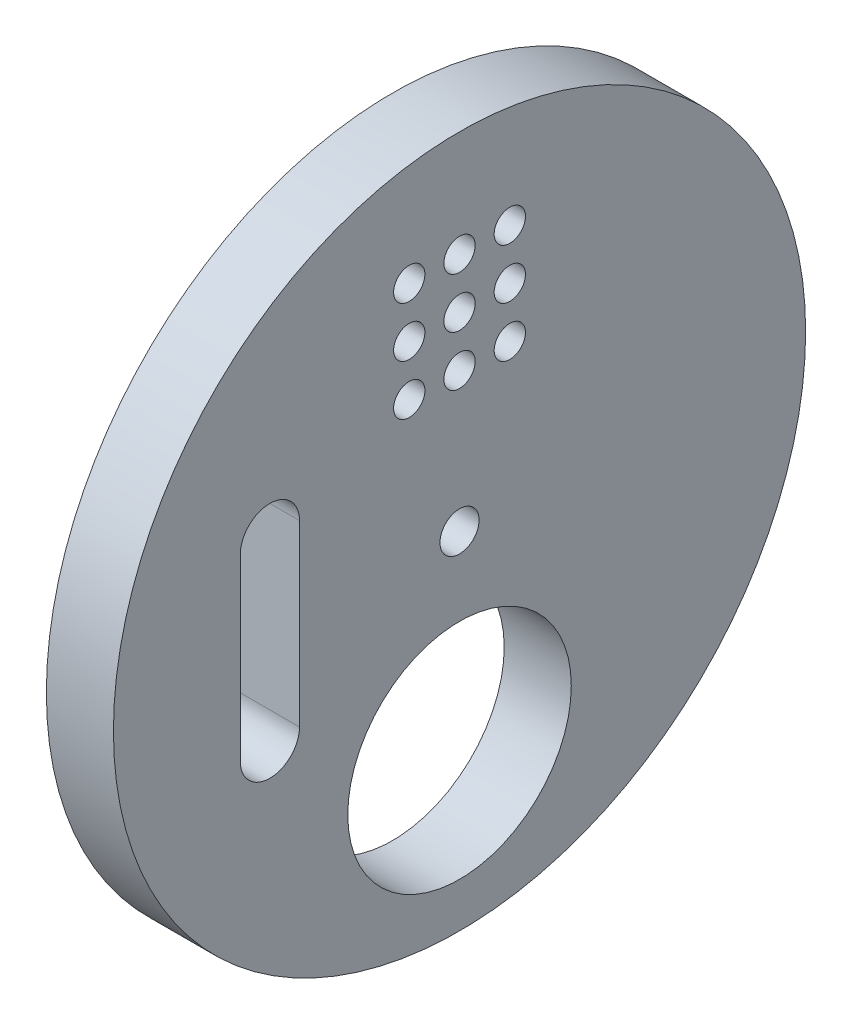
from build123d import *

# Parameters (mm, degrees)
SKETCH1_W           = 112.5
SKETCH1_H           = 238
BOSS_EXTRUDE1_DEPTH = 6
SKETCH2_R           = 30.970562748
SKETCH2_R_2         = 10
SKETCH2_R_3         = 1.4
SKETCH2_R_4         = 1.75
BOSS_EXTRUDE2_DEPTH = 6
SKETCH3_W           = 112.5
SKETCH3_H           = 238
CUT_EXTRUDE1_DEPTH  = 6


with BuildPart() as part:
    # Sketch1 → Boss-Extrude1 (new body)
    with BuildSketch(Plane(origin=(0, 0, 0), x_dir=(0, 0, -1), z_dir=(1, 0, 0))):
        Rectangle(SKETCH1_W, SKETCH1_H)
    extrude(amount=BOSS_EXTRUDE1_DEPTH)

    # Sketch2 → Boss-Extrude2 (add)
    with BuildSketch(Plane(origin=(6, 0, 0), x_dir=(0, 0, -1), z_dir=(1, 0, 0))):
        with Locations((0, -82.029437252)):
            Circle(SKETCH2_R)
        with Locations((0, -99)):
            Circle(SKETCH2_R_2, mode=Mode.SUBTRACT)
        with Locations((-4.5, -60.558874503)):
            Circle(SKETCH2_R_3, mode=Mode.SUBTRACT)
        with Locations((0, -60.558874503)):
            Circle(SKETCH2_R_3, mode=Mode.SUBTRACT)
        with Locations((4.5, -60.558874503)):
            Circle(SKETCH2_R_3, mode=Mode.SUBTRACT)
        with Locations((0, -65.058874503)):
            Circle(SKETCH2_R_3, mode=Mode.SUBTRACT)
        with Locations((4.5, -65.058874503)):
            Circle(SKETCH2_R_3, mode=Mode.SUBTRACT)
        with Locations((0, -69.558874503)):
            Circle(SKETCH2_R_3, mode=Mode.SUBTRACT)
        with Locations((4.5, -69.558874503)):
            Circle(SKETCH2_R_3, mode=Mode.SUBTRACT)
        with Locations((-4.5, -65.058874503)):
            Circle(SKETCH2_R_3, mode=Mode.SUBTRACT)
        with Locations((-4.5, -69.558874503)):
            Circle(SKETCH2_R_3, mode=Mode.SUBTRACT)
        with Locations((0, -82.029437252)):
            Circle(SKETCH2_R_4, mode=Mode.SUBTRACT)
        with BuildLine():
            Line((-14.320562748, -74.029437252), (-14.320562748, -90.029437252))
            ThreePointArc((-14.320562748, -90.029437252), (-16.970562748, -92.679437252), (-19.620562748, -90.029437252))
            Line((-19.620562748, -90.029437252), (-19.620562748, -74.029437252))
            ThreePointArc((-19.620562748, -74.029437252), (-16.970562748, -71.379437252), (-14.320562748, -74.029437252))
        make_face(mode=Mode.SUBTRACT)
    extrude(amount=BOSS_EXTRUDE2_DEPTH)

    # Sketch3 → Cut-Extrude1 (cut)
    with BuildSketch(Plane.ZY):
        Rectangle(SKETCH3_W, SKETCH3_H)
    extrude(amount=-CUT_EXTRUDE1_DEPTH, mode=Mode.SUBTRACT)


solid = part.part
